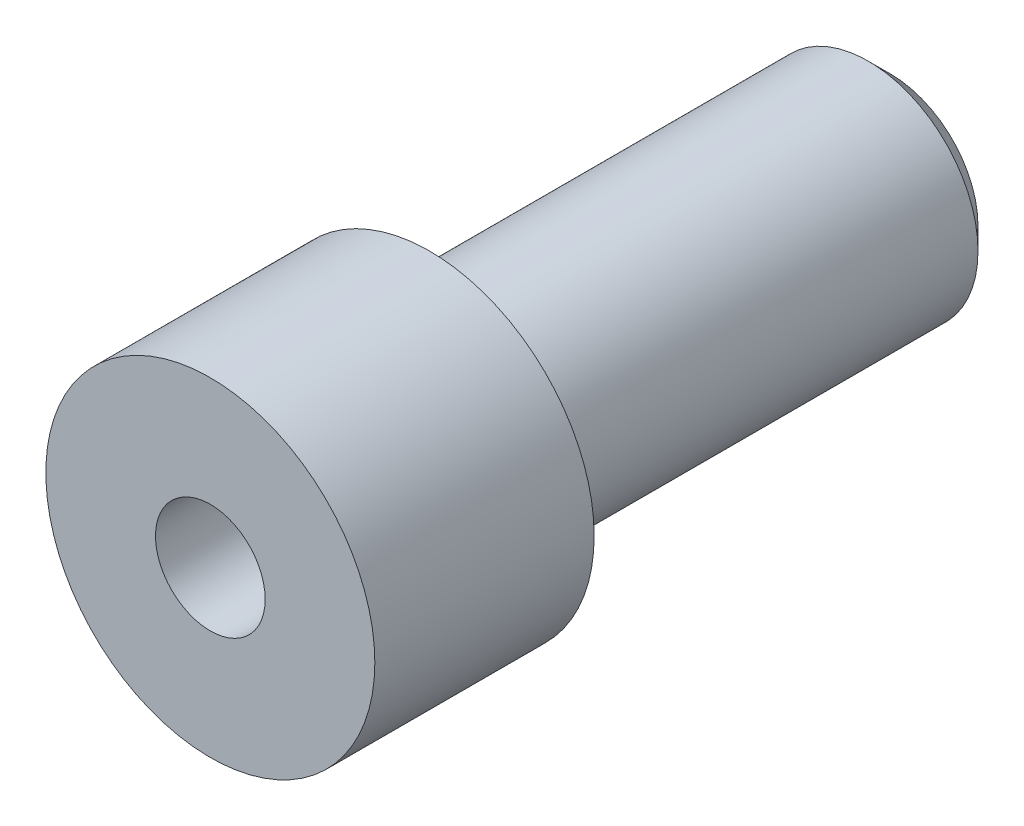
from build123d import *

# Parameters (mm, degrees)
SKETCH_1_R      = 1.5
EXTRUDE_1_DEPTH = 2
SKETCH_2_R      = 1
EXTRUDE_2_DEPTH = 4.2
CHAMFER_1_SIZE  = 0.2
MM_1_D          = 1
MM_1_DEPTH      = 5.2
MM_1_TIP        = 0.30043031


with BuildPart() as part:
    # 草图1 → 凸台-拉伸1 (new body)
    with BuildSketch(Plane.XY):
        Circle(SKETCH_1_R)
    extrude(amount=EXTRUDE_1_DEPTH)

    # 草图2 → 凸台-拉伸2 (add)
    with BuildSketch(Plane(origin=(0, 0, 0), x_dir=(-1, 0, 0), z_dir=(0, 0, -1))):
        Circle(SKETCH_2_R)
    extrude(amount=EXTRUDE_2_DEPTH)

    # 倒角1
    chamfer_1_edges = [part.edges().sort_by_distance(p)[0] for p in [
        (1, 0, -4.2),
    ]]
    chamfer(chamfer_1_edges, length=CHAMFER_1_SIZE)

    # 大小mm 暗销孔1
    with Locations(Plane.XY.offset(2)):
        with Locations((0, 0)):
            Hole(MM_1_D / 2, depth=MM_1_DEPTH)
            with Locations((0, 0, -(MM_1_DEPTH + MM_1_TIP / 2))):  # 118° drill point
                Cone(0, MM_1_D / 2, MM_1_TIP, mode=Mode.SUBTRACT)


solid = part.part
